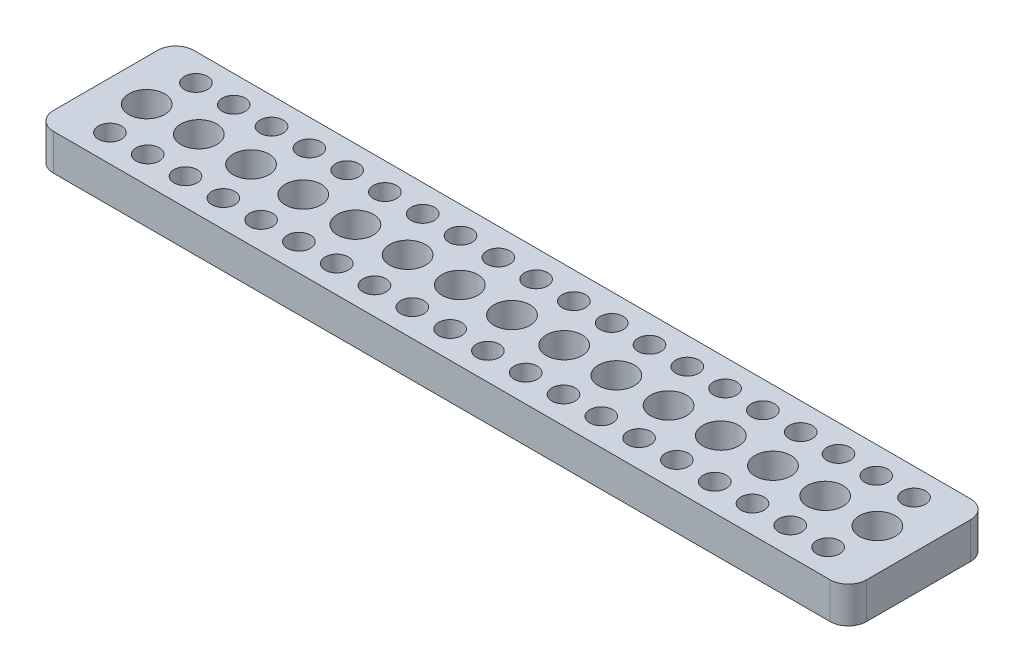
from build123d import *

# Parameters (mm, degrees)
SKETCH_1_W            = 179.605
SKETCH_1_H            = 31
EXTRUDE_1_DEPTH       = 8
HOLE_WIZARD_1_4_201_D = 5.1054
HOLE_WIZARD_3_8_161_D = 7.9375
FILLET_1_R            = 4


with BuildPart() as part:
    # Эскиз1 → Бобышка-Вытянуть1 (new body)
    with BuildSketch(Plane(origin=(0, 0, 0), x_dir=(1, 0, 0), z_dir=(0, 1, 0))):
        with Locations((89.8025, 15.5)):
            Rectangle(SKETCH_1_W, SKETCH_1_H)
    extrude(amount=EXTRUDE_1_DEPTH)

    # Отверстие обработанное метчиком 1/4-201 (through all)
    with Locations(Plane(origin=(0, 0, 0), x_dir=(-1, 0, 0), z_dir=(0, -1, 0))):
        with Locations((-10.475, 25), (-18.825, 25), (-27.175, 25), (-35.525, 25), (-43.875, 25), (-52.225, 25), (-60.575, 25), (-68.925, 25), (-77.275, 25), (-85.625, 25), (-93.975, 25), (-102.325, 25), (-110.675, 25), (-119.025, 25), (-127.375, 25), (-135.725, 25), (-144.075, 25), (-152.425, 25), (-160.775, 25), (-169.125, 25), (-169.125, 6), (-160.775, 6), (-152.425, 6), (-144.075, 6), (-135.725, 6), (-127.375, 6), (-119.025, 6), (-110.675, 6), (-102.325, 6), (-93.975, 6), (-85.625, 6), (-77.275, 6), (-68.925, 6), (-60.575, 6), (-52.225, 6), (-43.875, 6), (-35.525, 6), (-27.175, 6), (-18.825, 6), (-10.475, 6)):
            Hole(HOLE_WIZARD_1_4_201_D / 2)

    # Отверстие обработанное метчиком 3/8-161 (through all)
    with Locations(Plane(origin=(0, 0, 0), x_dir=(-1, 0, 0), z_dir=(0, -1, 0))):
        with Locations((-9.095, 15.5), (-20.62, 15.5), (-32.15, 15.5), (-43.68, 15.5), (-55.21, 15.5), (-66.74, 15.5), (-78.27, 15.5), (-89.8, 15.5), (-101.33, 15.5), (-112.86, 15.5), (-124.39, 15.5), (-135.92, 15.5), (-147.45, 15.5), (-158.98, 15.5), (-170.51, 15.5)):
            Hole(HOLE_WIZARD_3_8_161_D / 2)

    # Скругление1
    fillet_1_edges = [part.edges().sort_by_distance(p)[0] for p in [
        (0, 4, 0),
        (0, 4, -31),
        (179.605, 4, -31),
        (179.605, 4, 0),
    ]]
    fillet(fillet_1_edges, radius=FILLET_1_R)


solid = part.part
